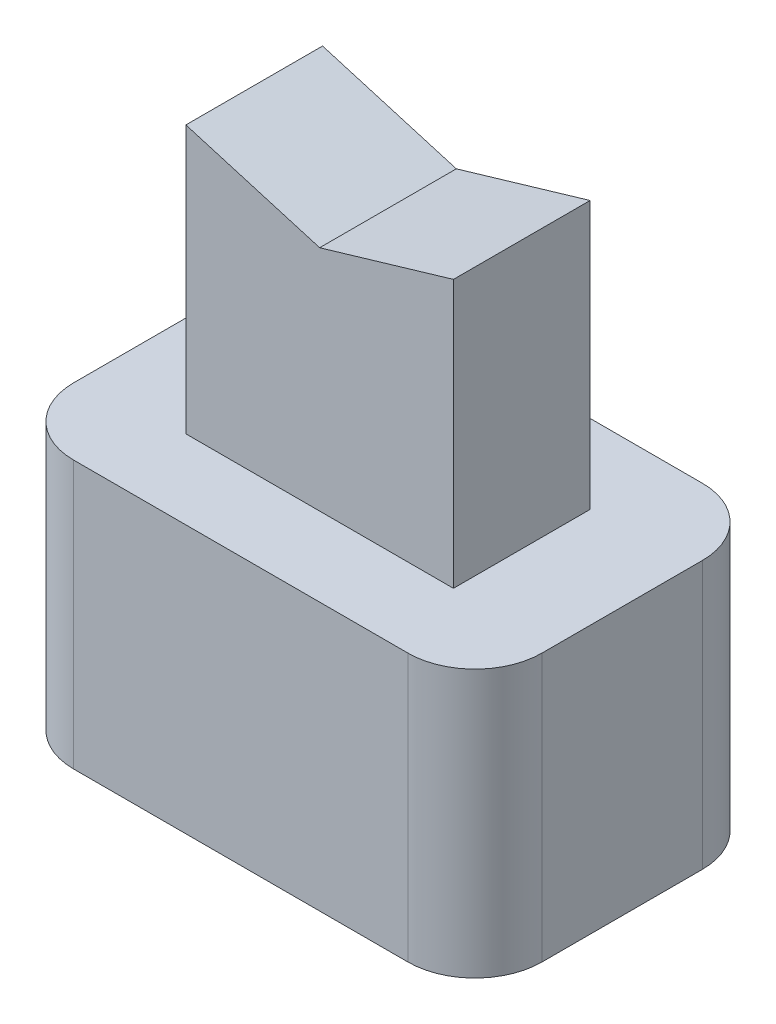
from build123d import *

# Parameters (mm, degrees)
CROQUIS1_W                 = 7
CROQUIS1_H                 = 4.4
SALIENTE_EXTRUIR1_DEPTH    = 8
CROQUIS2_OUTSIDE_W         = 11.3
CROQUIS2_OUTSIDE_H         = 8.7
CROQUIS2_OUTSIDE_W_2       = 4
CROQUIS2_OUTSIDE_H_2       = 2.04309095
CORTAR_EXTRUIR1_DEPTH      = 4
REDONDEO1_R                = 1
CORTAR_EXTRUIR2_DEPTH      = 2.178454525
CORTAR_EXTRUIR2_DEPTH_BACK = 4.221545475


with BuildPart() as part:
    # Croquis1 → Saliente-Extruir1 (new body)
    with BuildSketch(Plane(origin=(0, 0, 0), x_dir=(1, 0, 0), z_dir=(0, 1, 0))):
        Rectangle(CROQUIS1_W, CROQUIS1_H)
    extrude(amount=SALIENTE_EXTRUIR1_DEPTH)

    # Croquis2 outside → Cortar-Extruir1 (cut)
    with BuildSketch(Plane(origin=(0, 8, 0), x_dir=(1, 0, 0), z_dir=(0, 1, 0))):
        Rectangle(CROQUIS2_OUTSIDE_W, CROQUIS2_OUTSIDE_H)
        Rectangle(CROQUIS2_OUTSIDE_W_2, CROQUIS2_OUTSIDE_H_2, mode=Mode.SUBTRACT)
    extrude(amount=-CORTAR_EXTRUIR1_DEPTH, mode=Mode.SUBTRACT)

    # Redondeo1
    redondeo1_edges = [part.edges().sort_by_distance(p)[0] for p in [
        (3.5, 2, 2.2),
        (-3.5, 2, 2.2),
        (-3.5, 2, -2.2),
        (3.5, 2, -2.2),
    ]]
    fillet(redondeo1_edges, radius=REDONDEO1_R)

    # Croquis3 → Cortar-Extruir2 (cut, two sides)
    with BuildSketch(Plane.XY.offset(1.021545475)) as cortar_extruir2_sk:
        Polygon((-30.213727446, 16.325583484), (-2, 8), (0, 7.409820379), (2, 8), (30.213727446, 16.325583484), (30.213727446, 75.158559162), (-30.213727446, 75.158559162), align=None)
    extrude(amount=CORTAR_EXTRUIR2_DEPTH, mode=Mode.SUBTRACT)
    extrude(cortar_extruir2_sk.sketch, amount=-CORTAR_EXTRUIR2_DEPTH_BACK, mode=Mode.SUBTRACT)


solid = part.part
